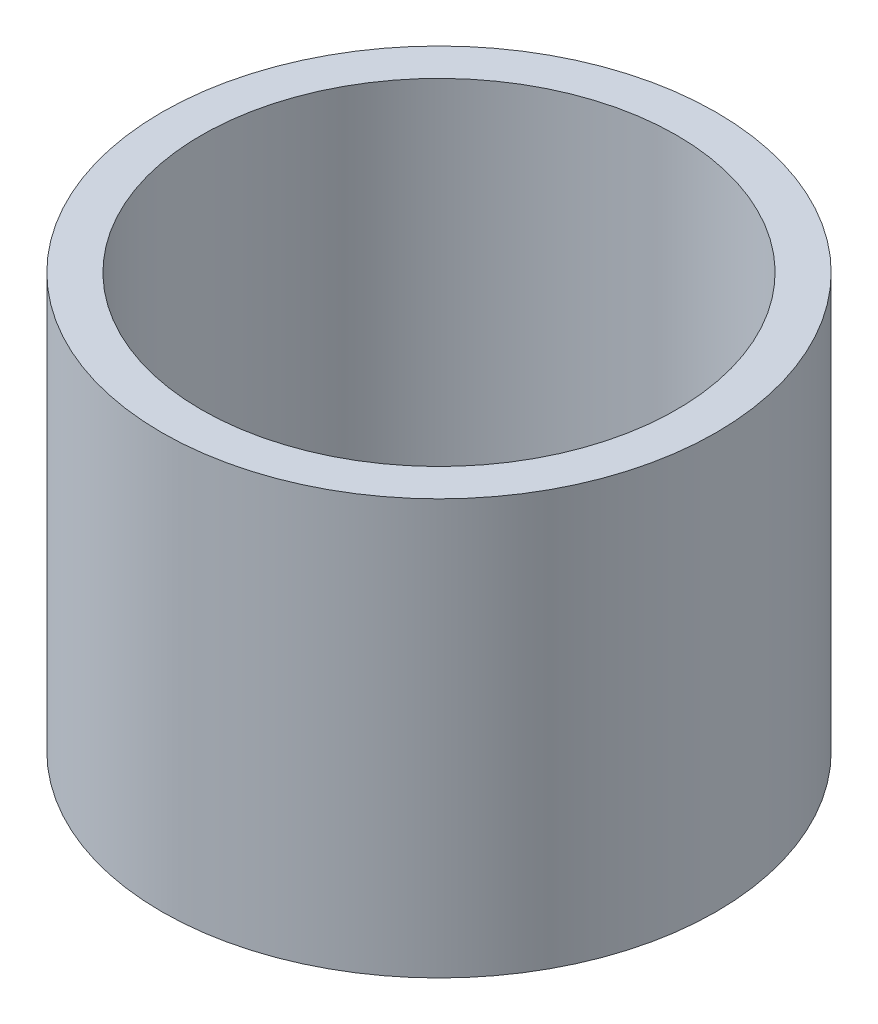
from build123d import *

# Parameters (mm, degrees)
SKETCH1_R           = 30.075
SKETCH1_R_2         = 25.775
BOSS_EXTRUDE1_DEPTH = 45


with BuildPart() as part:
    # Sketch1 → Boss-Extrude1 (new body)
    with BuildSketch(Plane(origin=(0, 0, 0), x_dir=(1, 0, 0), z_dir=(0, 1, 0))):
        Circle(SKETCH1_R)
        Circle(SKETCH1_R_2, mode=Mode.SUBTRACT)
    extrude(amount=BOSS_EXTRUDE1_DEPTH)


solid = part.part
